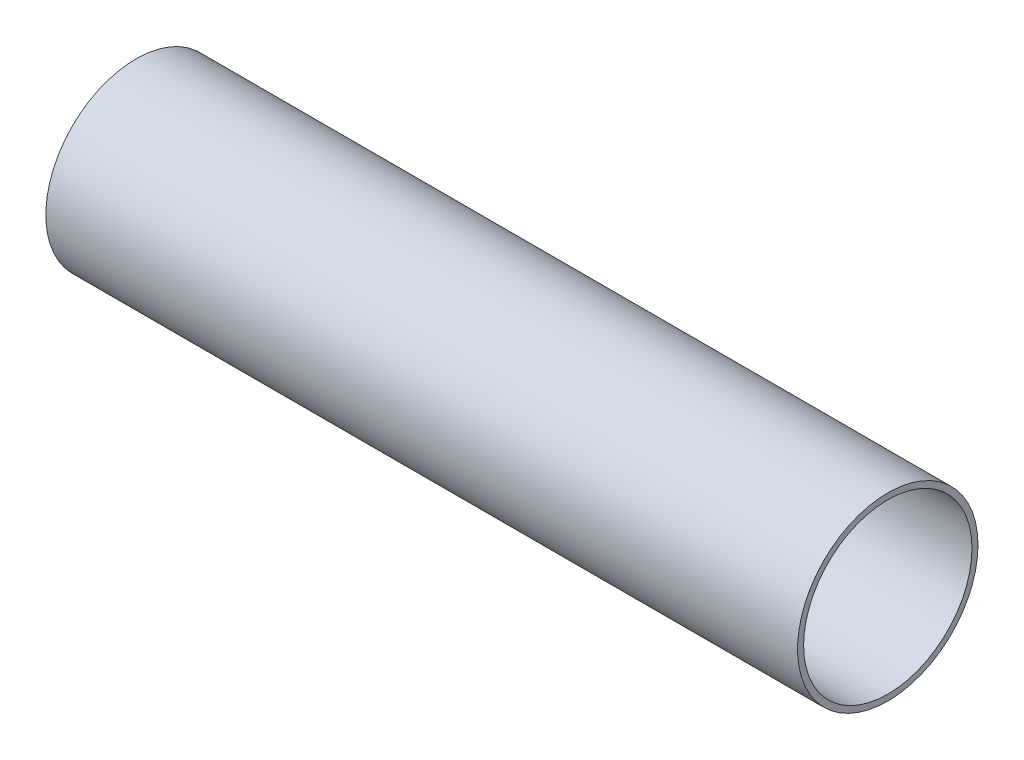
from build123d import *

# Parameters (mm, degrees)
SKETCH1_R           = 30
BOSS_EXTRUDE1_DEPTH = 250
SKETCH2_R           = 28
CUT_EXTRUDE1_DEPTH  = 250


with BuildPart() as part:
    # Sketch1 → Boss-Extrude1 (new body)
    with BuildSketch(Plane(origin=(0, 0, 0), x_dir=(0, 0, -1), z_dir=(1, 0, 0))):
        Circle(SKETCH1_R)
    extrude(amount=BOSS_EXTRUDE1_DEPTH)

    # Sketch2 → Cut-Extrude1 (cut)
    with BuildSketch(Plane(origin=(250, 0, 0), x_dir=(0, 0, -1), z_dir=(1, 0, 0))):
        Circle(SKETCH2_R)
    extrude(amount=-CUT_EXTRUDE1_DEPTH, mode=Mode.SUBTRACT)


solid = part.part
